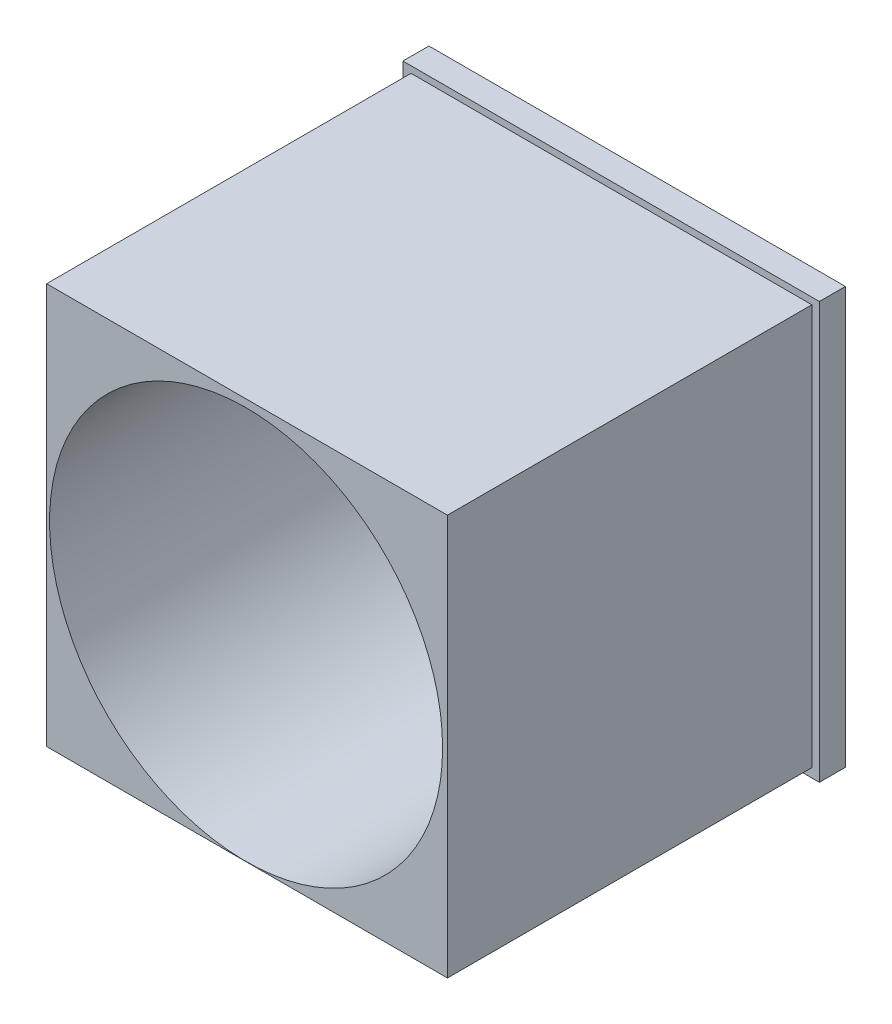
from build123d import *

# Parameters (mm, degrees)
SKETCH2_W           = 40.64
SKETCH2_H           = 40.64
BOSS_EXTRUDE1_DEPTH = 38.1
SKETCH3_W           = 40.64
SKETCH3_H           = 40.64
SKETCH3_W_2         = 39.116
SKETCH3_H_2         = 39.116
CUT_EXTRUDE1_DEPTH  = 35.56
SKETCH4_R           = 19.177
CUT_EXTRUDE3_DEPTH  = 35.56


with BuildPart() as part:
    # Sketch2 → Boss-Extrude1 (new body)
    with BuildSketch(Plane.XY):
        with Locations((0.436989247, 1.966451613)):
            Rectangle(SKETCH2_W, SKETCH2_H)
    extrude(amount=BOSS_EXTRUDE1_DEPTH)

    # Sketch3 → Cut-Extrude1 (cut)
    with BuildSketch(Plane.XY.offset(38.1)):
        with Locations((0.436989247, 1.966451613)):
            Rectangle(SKETCH3_W, SKETCH3_H)
        with Locations((0.466860662, 2.084424142)):
            Rectangle(SKETCH3_W_2, SKETCH3_H_2, mode=Mode.SUBTRACT)
    extrude(amount=-CUT_EXTRUDE1_DEPTH, mode=Mode.SUBTRACT)

    # Sketch4 → Cut-Extrude3 (cut)
    with BuildSketch(Plane.XY.offset(38.1)):
        with Locations((0.37530299, 1.719706585)):
            Circle(SKETCH4_R)
    extrude(amount=-CUT_EXTRUDE3_DEPTH, mode=Mode.SUBTRACT)


solid = part.part
